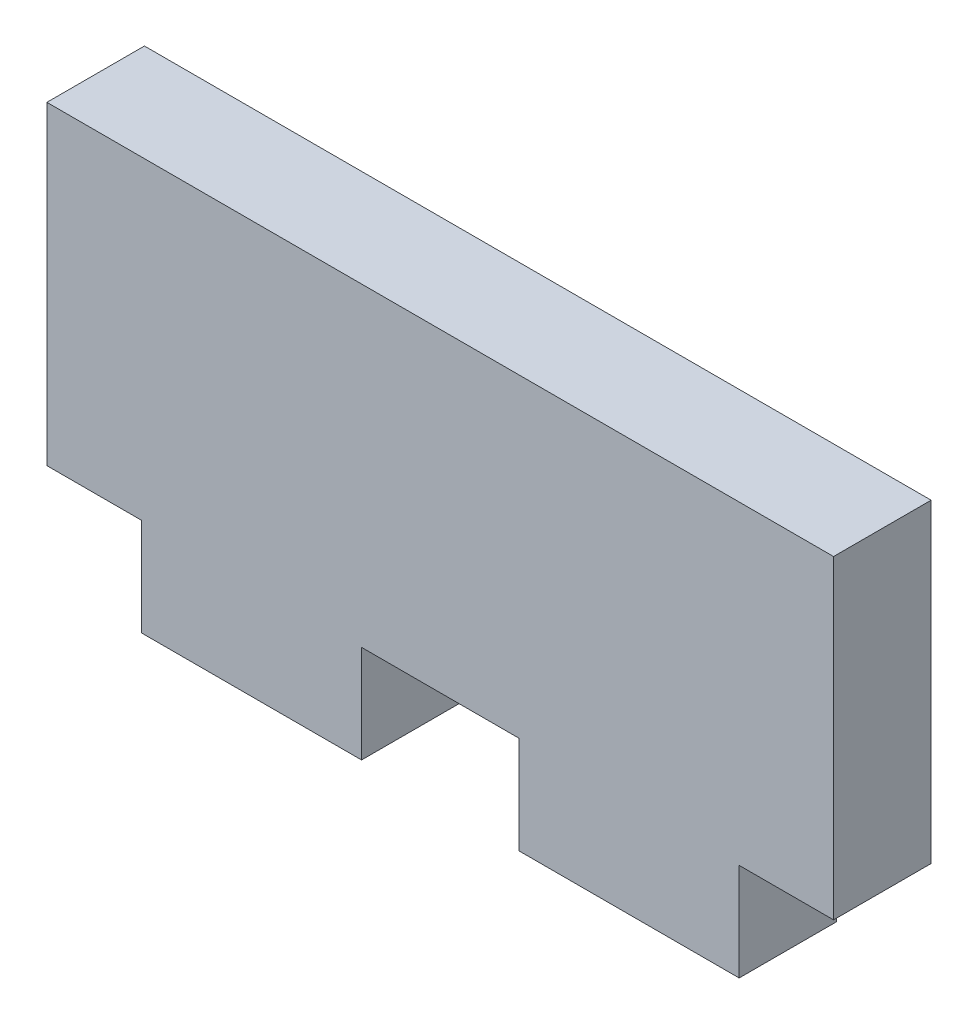
from build123d import *

# Parameters (mm, degrees)
SKETCH_1_W      = 25
SKETCH_1_H      = 10
SKETCH_1_W_2    = 7
SKETCH_1_H_2    = 3.1
EXTRUDE_1_DEPTH = 3.1


with BuildPart() as part:
    # 草图1 → 凸台-拉伸1 (new body)
    with BuildSketch(Plane.XY):
        Rectangle(SKETCH_1_W, SKETCH_1_H)
        with Locations((-6, -6.55)):
            Rectangle(SKETCH_1_W_2, SKETCH_1_H_2)
        with Locations((6, -6.55)):
            Rectangle(SKETCH_1_W_2, SKETCH_1_H_2)
    extrude(amount=EXTRUDE_1_DEPTH)


solid = part.part
